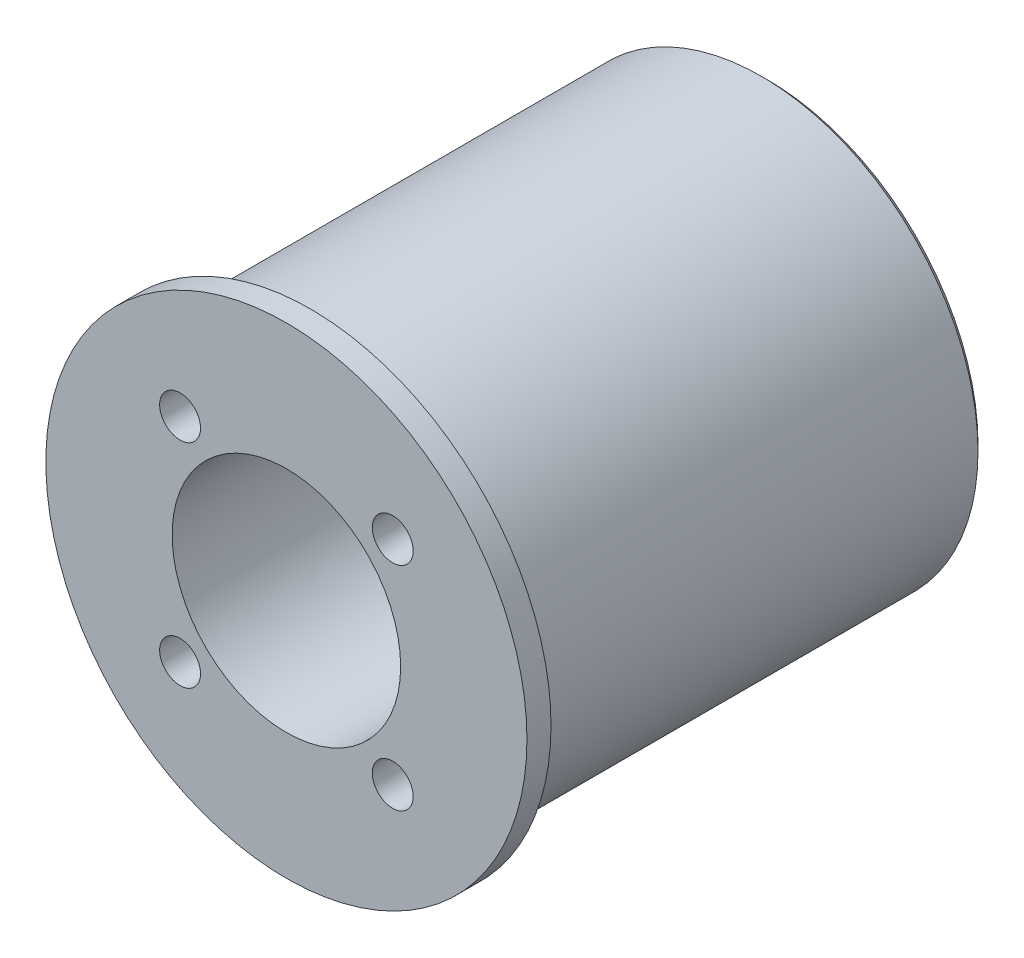
from build123d import *

# Parameters (mm, degrees)
ESQUISSE1_R                                         = 18
BOSS_EXTRU_1_DEPTH                                  = 40
SKETCH1_R                                           = 20
BOSS_EXTRUDE1_DEPTH                                 = 2
CBORE_FOR_M3_HEX_SOCKET_HEAD_CAP_SCREW1_D           = 3.4
CBORE_FOR_M3_HEX_SOCKET_HEAD_CAP_SCREW1_CBORE_D     = 6.5
CBORE_FOR_M3_HEX_SOCKET_HEAD_CAP_SCREW1_CBORE_DEPTH = 3.4
ESQUISSE5_R                                         = 9.5
ENL_V_MAT_EXTRU_1_DEPTH                             = 35
ESQUISSE6_R                                         = 8
CUT_EXTRUDE2_DEPTH                                  = 41
CHAMFER1_SIZE                                       = 0.5


with BuildPart() as part:
    # Esquisse1 → Boss.-Extru.1 (new body)
    with BuildSketch(Plane.XY):
        Circle(ESQUISSE1_R)
    extrude(amount=BOSS_EXTRU_1_DEPTH)

    # Sketch1 → Boss-Extrude1 (add)
    with BuildSketch(Plane.XY.offset(40)):
        Circle(SKETCH1_R)
    extrude(amount=-BOSS_EXTRUDE1_DEPTH)

    # CBORE for M3 Hex Socket Head Cap Screw1 (through all)
    with Locations(Plane(origin=(0, 0, 0), x_dir=(-1, 0, 0), z_dir=(0, 0, -1))):
        with Locations((-8.838834765, -8.838834765), (-8.838834765, 8.838834765), (8.838834765, -8.838834765), (8.838834765, 8.838834765), (0, 0)):
            CounterBoreHole(CBORE_FOR_M3_HEX_SOCKET_HEAD_CAP_SCREW1_D / 2, CBORE_FOR_M3_HEX_SOCKET_HEAD_CAP_SCREW1_CBORE_D / 2, CBORE_FOR_M3_HEX_SOCKET_HEAD_CAP_SCREW1_CBORE_DEPTH)

    # Esquisse5 → Enlèv. mat.-Extru.1 (cut)
    with BuildSketch(Plane.XY.offset(40)):
        Circle(ESQUISSE5_R)
    extrude(amount=-ENL_V_MAT_EXTRU_1_DEPTH, mode=Mode.SUBTRACT)

    # Esquisse6 → Cut-Extrude2 (cut, through all)
    with BuildSketch(Plane(origin=(0, 0, 0), x_dir=(-1, 0, 0), z_dir=(0, 0, -1))):
        Circle(ESQUISSE6_R)
    extrude(amount=-CUT_EXTRUDE2_DEPTH, mode=Mode.SUBTRACT)

    # Chamfer1
    chamfer1_edges = [part.edges().sort_by_distance(p)[0] for p in [
        (-18, 0, 0),
    ]]
    chamfer(chamfer1_edges, length=CHAMFER1_SIZE)


solid = part.part
